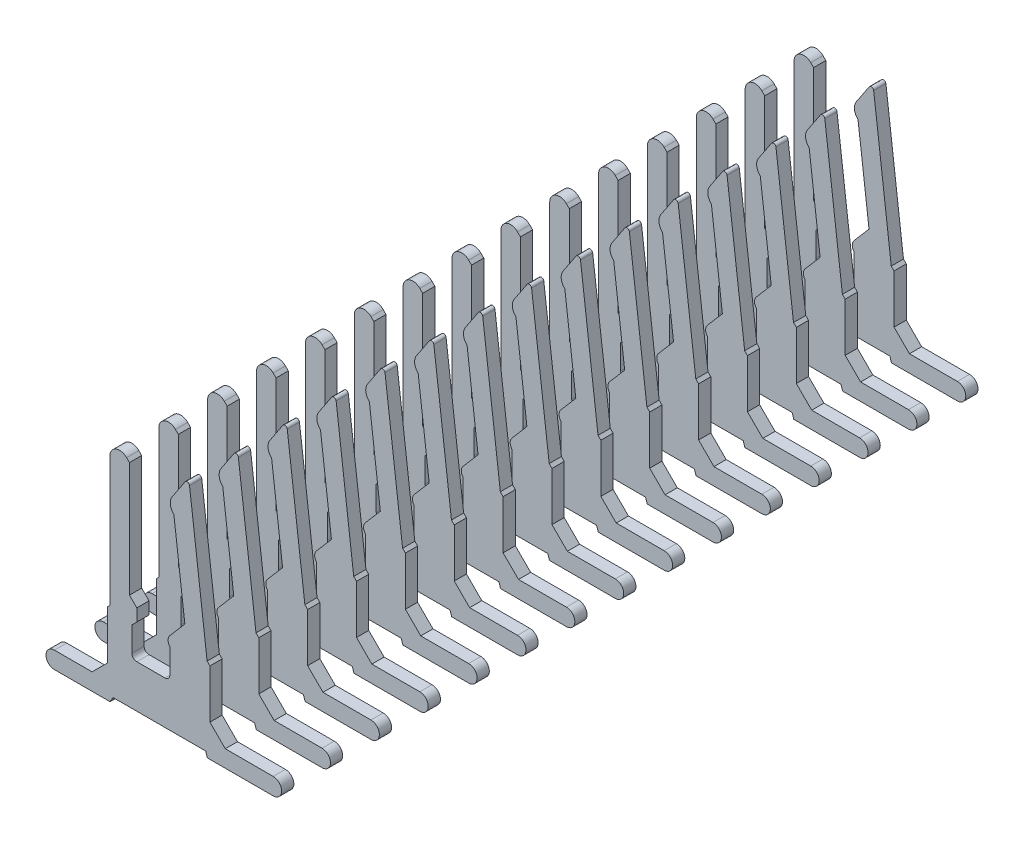
from build123d import *

# Parameters (mm, degrees)
BOSS_EXTRUDE1_DEPTH = 0.25
LPATTERN1_COUNT     = 15
LPATTERN1_PITCH     = 1


with BuildPart() as part:
    # Sketch1 → Boss-Extrude1 (new body)
    with BuildSketch(Plane.XY):
        with BuildLine():
            Line((1.154322642, 1.455960262), (1.096896052, 1.513386852))
            Line((1.096896052, 1.513386852), (0.737090693, 4.443766345))
            ThreePointArc((0.737090693, 4.443766345), (0.698972986, 4.486330139), (0.645825415, 4.465354631))
            Line((0.645825415, 4.465354631), (0.380448166, 4.066183018))
            ThreePointArc((0.380448166, 4.066183018), (0.344114023, 3.912579084), (0.416529041, 3.772327869))
            Line((0.416529041, 3.772327869), (0.641397744, 1.940919256))
            Line((0.641397744, 1.940919256), (0.334482222, 1.583614618))
            ThreePointArc((0.334482222, 1.583614618), (0.298267676, 1.485875831), (0.334482222, 1.388137044))
            Line((0.334482222, 1.388137044), (0.334482222, 0.883200693))
            ThreePointArc((0.334482222, 0.883200693), (0.3051929, 0.812490014), (0.234482222, 0.783200693))
            Line((0.234482222, 0.783200693), (-0.342129009, 0.783200693))
            ThreePointArc((-0.342129009, 0.783200693), (-0.412839687, 0.812490014), (-0.442129009, 0.883200693))
            Line((-0.442129009, 0.883200693), (-0.442129009, 1.384895673))
            Line((-0.442129009, 1.384895673), (-0.342129009, 1.484895673))
            Line((-0.342129009, 1.484895673), (-0.342129009, 1.7373543))
            Line((-0.342129009, 1.7373543), (-0.492129009, 1.8873543))
            Line((-0.492129009, 1.8873543), (-0.492129009, 4.236890131))
            Line((-0.492129009, 4.236890131), (-0.550707653, 4.295468774))
            ThreePointArc((-0.550707653, 4.295468774), (-0.768665696, 4.338823325), (-0.892129009, 4.154047418))
            Line((-0.892129009, 4.154047418), (-0.892129009, 1.505960262))
            Line((-0.892129009, 1.505960262), (-0.942129009, 1.455960262))
            Line((-0.942129009, 1.455960262), (-0.942129009, 0.46038227))
            Line((-0.942129009, 0.46038227), (-1.256596757, 0.145914522))
            Line((-1.256596757, 0.145914522), (-2.027042739, 0.145914522))
            ThreePointArc((-2.027042739, 0.145914522), (-2.2, -0.027042739), (-2.027042739, -0.2))
            Line((-2.027042739, -0.2), (-0.889717718, -0.2))
            Line((-0.889717718, -0.2), (-0.829198372, -0.095177417))
            Line((-0.829198372, -0.095177417), (1.068090373, -0.095177417))
            Line((1.068090373, -0.095177417), (1.101911351, -0.2))
            Line((1.101911351, -0.2), (2.448881537, -0.2))
            ThreePointArc((2.448881537, -0.2), (2.621838798, -0.027042739), (2.448881537, 0.145914522))
            Line((2.448881537, 0.145914522), (1.46879039, 0.145914522))
            Line((1.46879039, 0.145914522), (1.154322642, 0.46038227))
            Line((1.154322642, 0.46038227), (1.154322642, 1.455960262))
        make_face()
    extrude(amount=BOSS_EXTRUDE1_DEPTH)


with BuildPart() as lpattern1_1:
    # LPattern1: pattern copy
    add(part.part.moved(Location(Vector(0, 0, -1) * (1 * LPATTERN1_PITCH))))


with BuildPart() as lpattern1_2:
    # LPattern1: pattern copy
    add(part.part.moved(Location(Vector(0, 0, -1) * (2 * LPATTERN1_PITCH))))


with BuildPart() as lpattern1_3:
    # LPattern1: pattern copy
    add(part.part.moved(Location(Vector(0, 0, -1) * (3 * LPATTERN1_PITCH))))


with BuildPart() as lpattern1_4:
    # LPattern1: pattern copy
    add(part.part.moved(Location(Vector(0, 0, -1) * (4 * LPATTERN1_PITCH))))


with BuildPart() as lpattern1_5:
    # LPattern1: pattern copy
    add(part.part.moved(Location(Vector(0, 0, -1) * (5 * LPATTERN1_PITCH))))


with BuildPart() as lpattern1_6:
    # LPattern1: pattern copy
    add(part.part.moved(Location(Vector(0, 0, -1) * (6 * LPATTERN1_PITCH))))


with BuildPart() as lpattern1_7:
    # LPattern1: pattern copy
    add(part.part.moved(Location(Vector(0, 0, -1) * (7 * LPATTERN1_PITCH))))


with BuildPart() as lpattern1_8:
    # LPattern1: pattern copy
    add(part.part.moved(Location(Vector(0, 0, -1) * (8 * LPATTERN1_PITCH))))


with BuildPart() as lpattern1_9:
    # LPattern1: pattern copy
    add(part.part.moved(Location(Vector(0, 0, -1) * (9 * LPATTERN1_PITCH))))


with BuildPart() as lpattern1_10:
    # LPattern1: pattern copy
    add(part.part.moved(Location(Vector(0, 0, -1) * (10 * LPATTERN1_PITCH))))


with BuildPart() as lpattern1_11:
    # LPattern1: pattern copy
    add(part.part.moved(Location(Vector(0, 0, -1) * (11 * LPATTERN1_PITCH))))


with BuildPart() as lpattern1_12:
    # LPattern1: pattern copy
    add(part.part.moved(Location(Vector(0, 0, -1) * (12 * LPATTERN1_PITCH))))


with BuildPart() as lpattern1_13:
    # LPattern1: pattern copy
    add(part.part.moved(Location(Vector(0, 0, -1) * (13 * LPATTERN1_PITCH))))


with BuildPart() as lpattern1_14:
    # LPattern1: pattern copy
    add(part.part.moved(Location(Vector(0, 0, -1) * (14 * LPATTERN1_PITCH))))


solid = Compound([part.part, lpattern1_1.part, lpattern1_2.part, lpattern1_3.part, lpattern1_4.part, lpattern1_5.part, lpattern1_6.part, lpattern1_7.part, lpattern1_8.part, lpattern1_9.part, lpattern1_10.part, lpattern1_11.part, lpattern1_12.part, lpattern1_13.part, lpattern1_14.part])
